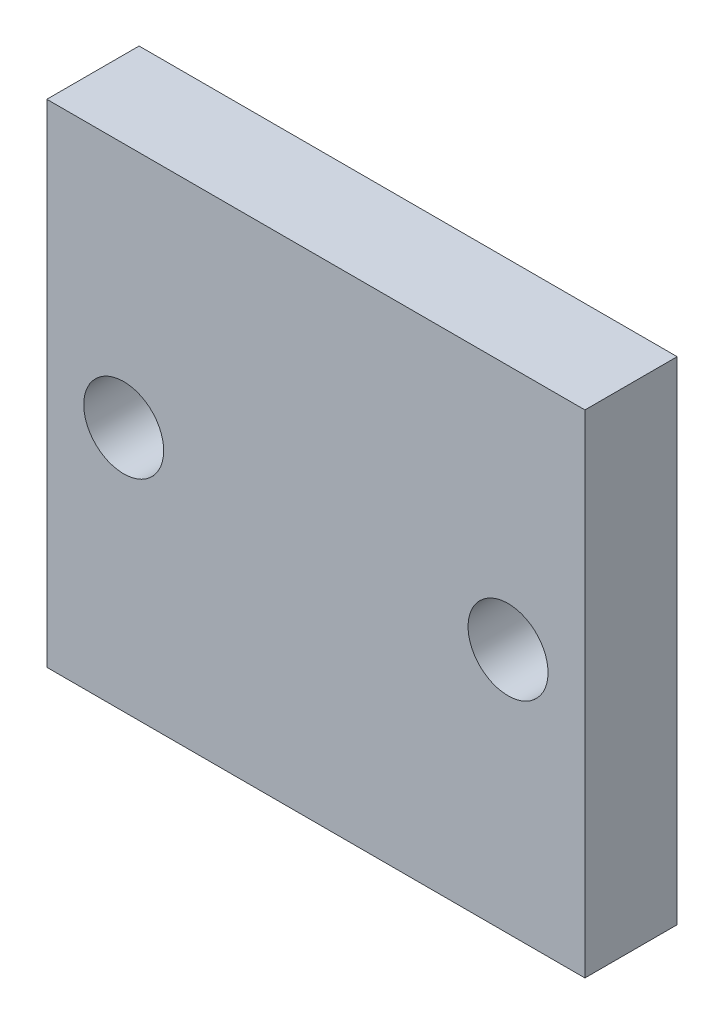
from build123d import *

# Parameters (mm, degrees)
ESBO_O1_W                = 35
ESBO_O1_H                = 32
ESBO_O1_R                = 2.6
RESSALTO_EXTRUS_O1_DEPTH = 6


with BuildPart() as part:
    # Esboço1 → Ressalto-extrusão1 (new body)
    with BuildSketch(Plane.XY):
        Rectangle(ESBO_O1_W, ESBO_O1_H)
        with Locations((-12.5, 0)):
            Circle(ESBO_O1_R, mode=Mode.SUBTRACT)
        with Locations((12.5, 0)):
            Circle(ESBO_O1_R, mode=Mode.SUBTRACT)
    extrude(amount=RESSALTO_EXTRUS_O1_DEPTH)


solid = part.part
